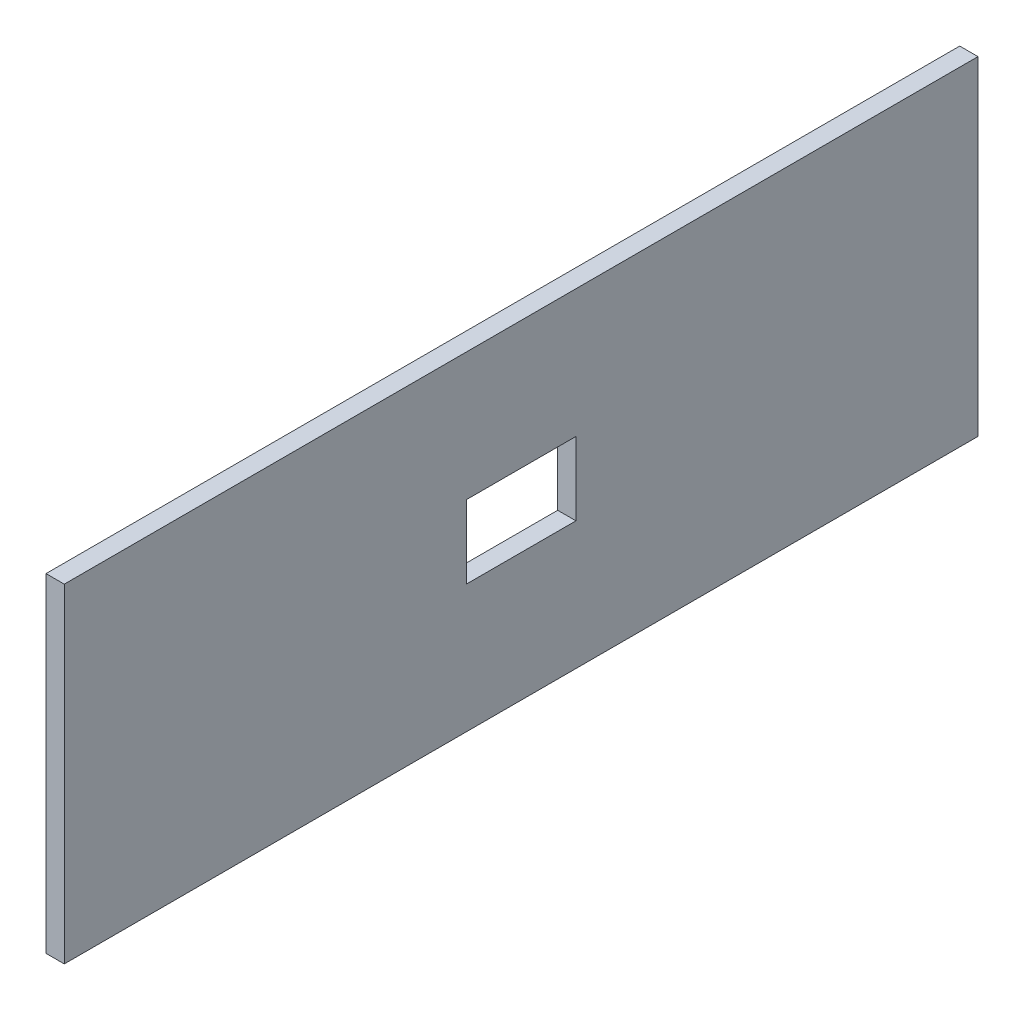
from build123d import *

# Parameters (mm, degrees)
SKETCH1_W           = 250
SKETCH1_H           = 90
BOSS_EXTRUDE1_DEPTH = 5
SKETCH2_W           = 30
SKETCH2_H           = 20
CUT_EXTRUDE1_DEPTH  = 10


with BuildPart() as part:
    # Sketch1 → Boss-Extrude1 (new body)
    with BuildSketch(Plane(origin=(0, 0, 0), x_dir=(0, 0, -1), z_dir=(1, 0, 0))):
        Rectangle(SKETCH1_W, SKETCH1_H)
    extrude(amount=BOSS_EXTRUDE1_DEPTH)

    # Sketch2 → Cut-Extrude1 (cut)
    with BuildSketch(Plane(origin=(5, 0, 0), x_dir=(0, 0, -1), z_dir=(1, 0, 0))):
        Rectangle(SKETCH2_W, SKETCH2_H)
    extrude(amount=-CUT_EXTRUDE1_DEPTH, mode=Mode.SUBTRACT)


solid = part.part
